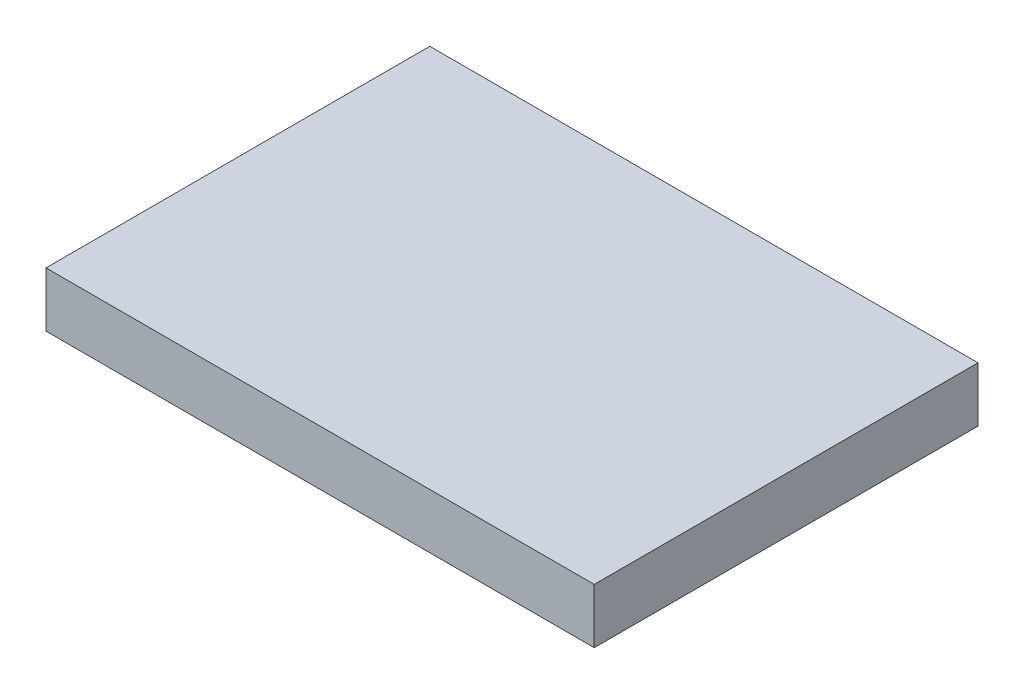
from build123d import *

# Parameters (mm, degrees)
SKETCH_1_W      = 100
SKETCH_1_H      = 70
EXTRUDE_1_DEPTH = 10


with BuildPart() as part:
    # Эскиз1 → Бобышка-Вытянуть1 (new body)
    with BuildSketch(Plane(origin=(0, 0, 0), x_dir=(1, 0, 0), z_dir=(0, 1, 0))):
        Rectangle(SKETCH_1_W, SKETCH_1_H)
    extrude(amount=EXTRUDE_1_DEPTH)


solid = part.part
